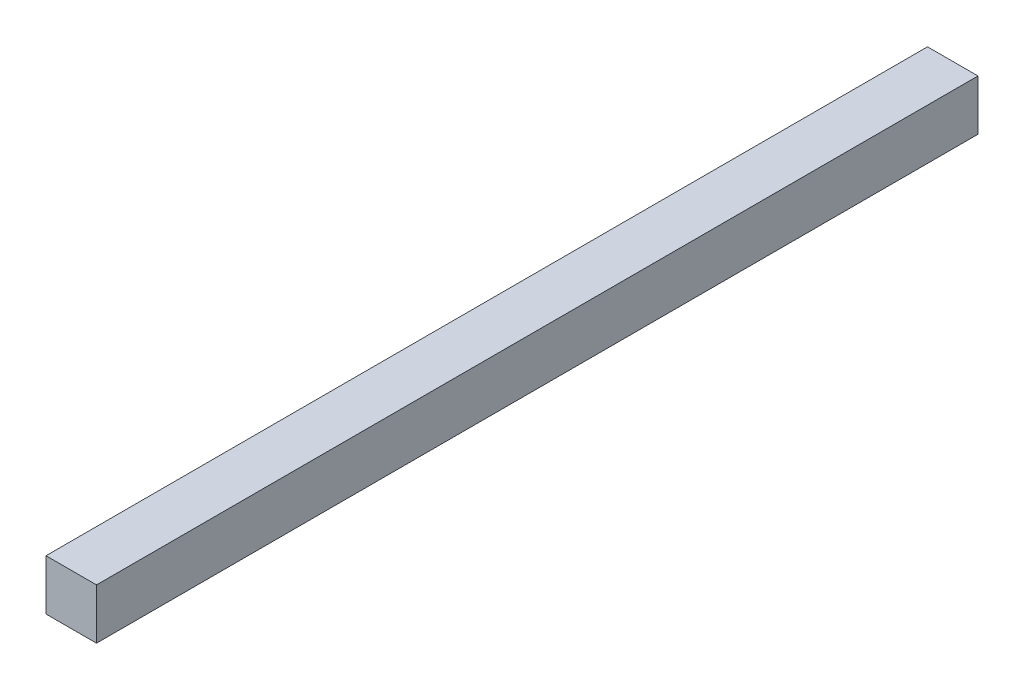
from build123d import *

# Parameters (mm, degrees)
SKETCH3_W           = 34.925
SKETCH3_H           = 34.925
BOSS_EXTRUDE1_DEPTH = 609.6


with BuildPart() as part:
    # Sketch3 → Boss-Extrude1 (new body)
    with BuildSketch(Plane.XY):
        Rectangle(SKETCH3_W, SKETCH3_H)
    extrude(amount=BOSS_EXTRUDE1_DEPTH)


solid = part.part
